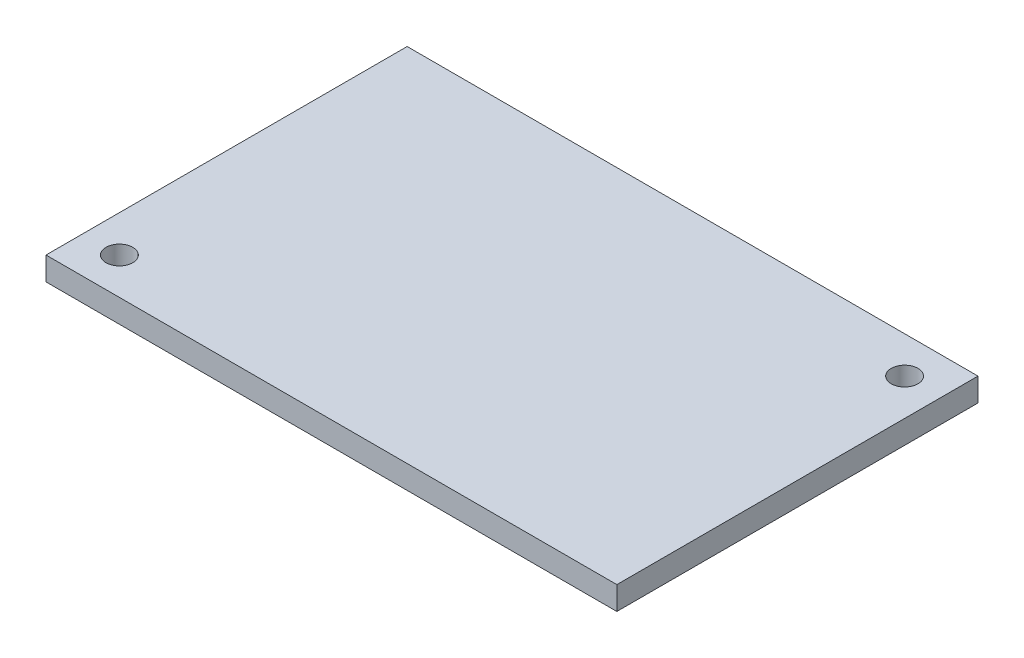
from build123d import *

# Parameters (mm, degrees)
SKETCH1_W           = 62.23
SKETCH1_H           = 2.54
BOSS_EXTRUDE1_DEPTH = 39.37
SKETCH2_R           = 1.4605
CUT_EXTRUDE1_DEPTH  = 3.54


with BuildPart() as part:
    # Sketch1 → Boss-Extrude1 (new body)
    with BuildSketch(Plane.XY):
        with Locations((31.115, 1.27)):
            Rectangle(SKETCH1_W, SKETCH1_H)
    extrude(amount=-BOSS_EXTRUDE1_DEPTH)

    # Sketch2 → Cut-Extrude1 (cut, through all)
    with BuildSketch(Plane(origin=(0, 2.54, 0), x_dir=(1, 0, 0), z_dir=(0, 1, 0))):
        with Locations((4.0005, 4.0005)):
            Circle(SKETCH2_R)
        with Locations((58.2295, 35.3695)):
            Circle(SKETCH2_R)
    extrude(amount=-CUT_EXTRUDE1_DEPTH, mode=Mode.SUBTRACT)


solid = part.part
